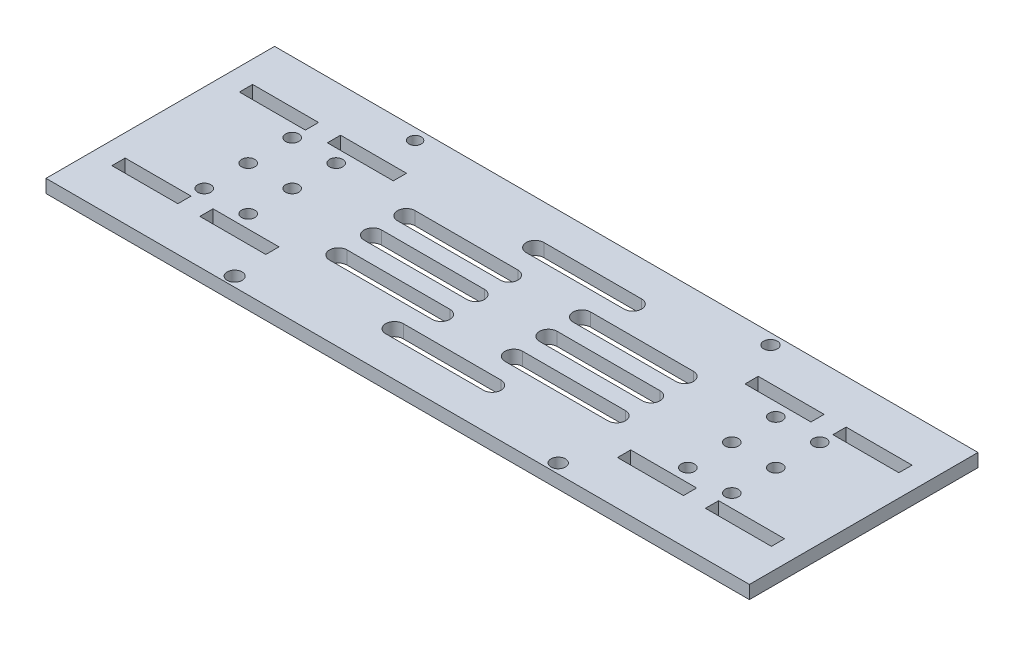
from build123d import *

# Parameters (mm, degrees)
SKETCH1_W           = 160
SKETCH1_H           = 52
SKETCH1_R           = 1.5
SKETCH1_W_2         = 15
SKETCH1_H_2         = 3
BOSS_EXTRUDE1_DEPTH = 3
CUT_EXTRUDE1_DEPTH  = 3
SKETCH3_R           = 1.63582752
SKETCH3_R_2         = 1.692495787
SKETCH3_R_3         = 1.410083192
SKETCH3_R_4         = 1.550817753
CUT_EXTRUDE2_DEPTH  = 10


with BuildPart() as part:
    # Sketch1 → Boss-Extrude1 (new body)
    with BuildSketch(Plane(origin=(0, 0, 0), x_dir=(1, 0, 0), z_dir=(0, 1, 0))):
        Rectangle(SKETCH1_W, SKETCH1_H)
        with Locations((50, 10)):
            Circle(SKETCH1_R, mode=Mode.SUBTRACT)
        with Locations((60, 10)):
            Circle(SKETCH1_R, mode=Mode.SUBTRACT)
        with Locations((60, 0)):
            Circle(SKETCH1_R, mode=Mode.SUBTRACT)
        with Locations((50, 0)):
            Circle(SKETCH1_R, mode=Mode.SUBTRACT)
        with Locations((50, -10)):
            Circle(SKETCH1_R, mode=Mode.SUBTRACT)
        with Locations((60, -10)):
            Circle(SKETCH1_R, mode=Mode.SUBTRACT)
        with Locations((-60, -10)):
            Circle(SKETCH1_R, mode=Mode.SUBTRACT)
        with Locations((-50, -10)):
            Circle(SKETCH1_R, mode=Mode.SUBTRACT)
        with Locations((-50, 0)):
            Circle(SKETCH1_R, mode=Mode.SUBTRACT)
        with Locations((-60, 0)):
            Circle(SKETCH1_R, mode=Mode.SUBTRACT)
        with Locations((-60, 10)):
            Circle(SKETCH1_R, mode=Mode.SUBTRACT)
        with Locations((-50, 10)):
            Circle(SKETCH1_R, mode=Mode.SUBTRACT)
        with Locations((67.5, 14.5)):
            Rectangle(SKETCH1_W_2, SKETCH1_H_2, mode=Mode.SUBTRACT)
        with Locations((47.5, 14.5)):
            Rectangle(SKETCH1_W_2, SKETCH1_H_2, mode=Mode.SUBTRACT)
        with Locations((67.5, -14.5)):
            Rectangle(SKETCH1_W_2, SKETCH1_H_2, mode=Mode.SUBTRACT)
        with Locations((47.5, -14.5)):
            Rectangle(SKETCH1_W_2, SKETCH1_H_2, mode=Mode.SUBTRACT)
        with Locations((-47.5, -14.5)):
            Rectangle(SKETCH1_W_2, SKETCH1_H_2, mode=Mode.SUBTRACT)
        with Locations((-67.5, -14.5)):
            Rectangle(SKETCH1_W_2, SKETCH1_H_2, mode=Mode.SUBTRACT)
        with Locations((-47.5, 14.5)):
            Rectangle(SKETCH1_W_2, SKETCH1_H_2, mode=Mode.SUBTRACT)
        with Locations((-67.5, 14.5)):
            Rectangle(SKETCH1_W_2, SKETCH1_H_2, mode=Mode.SUBTRACT)
    extrude(amount=BOSS_EXTRUDE1_DEPTH)

    # Sketch2 → Cut-Extrude1 (cut)
    with BuildSketch(Plane(origin=(0, 3, 0), x_dir=(1, 0, 0), z_dir=(0, 1, 0))):
        with BuildLine():
            Line((-31.658505885, 2), (-8.266387648, 2))
            ThreePointArc((-8.266387648, 2), (-6.266387648, 0), (-8.266387648, -2))
            Line((-8.266387648, -2), (-31.658505885, -2))
            ThreePointArc((-31.658505885, -2), (-33.658505885, 0), (-31.658505885, 2))
        make_face()
        with BuildLine():
            Line((31.658505885, -9.856733432), (8.266387648, -9.856733432))
            ThreePointArc((8.266387648, -9.856733432), (6.266387648, -7.856733432), (8.266387648, -5.856733432))
            Line((8.266387648, -5.856733432), (31.658505885, -5.856733432))
            ThreePointArc((31.658505885, -5.856733432), (33.658505885, -7.856733432), (31.658505885, -9.856733432))
        make_face()
        with BuildLine():
            Line((-10.747740664, 17.987567994), (11.499478158, 17.987567994))
            ThreePointArc((11.499478158, 17.987567994), (13.499478158, 15.987567994), (11.499478158, 13.987567994))
            Line((11.499478158, 13.987567994), (-10.747740664, 13.987567994))
            ThreePointArc((-10.747740664, 13.987567994), (-12.747740664, 15.987567994), (-10.747740664, 17.987567994))
        make_face()
        with BuildLine():
            Line((-31.658505885, 9.620758334), (-8.266387648, 9.620758334))
            ThreePointArc((-8.266387648, 9.620758334), (-6.266387648, 7.620758334), (-8.266387648, 5.620758334))
            Line((-8.266387648, 5.620758334), (-31.658505885, 5.620758334))
            ThreePointArc((-31.658505885, 5.620758334), (-33.658505885, 7.620758334), (-31.658505885, 9.620758334))
        make_face()
        with BuildLine():
            Line((31.658505885, 5.620758334), (8.266387648, 5.620758334))
            ThreePointArc((8.266387648, 5.620758334), (6.266387648, 7.620758334), (8.266387648, 9.620758334))
            Line((8.266387648, 9.620758334), (31.658505885, 9.620758334))
            ThreePointArc((31.658505885, 9.620758334), (33.658505885, 7.620758334), (31.658505885, 5.620758334))
        make_face()
        with BuildLine():
            Line((-31.658505885, -5.856733432), (-8.266387648, -5.856733432))
            ThreePointArc((-8.266387648, -5.856733432), (-6.266387648, -7.856733432), (-8.266387648, -9.856733432))
            Line((-8.266387648, -9.856733432), (-31.658505885, -9.856733432))
            ThreePointArc((-31.658505885, -9.856733432), (-33.658505885, -7.856733432), (-31.658505885, -5.856733432))
        make_face()
        with BuildLine():
            Line((31.658505885, -2), (8.266387648, -2))
            ThreePointArc((8.266387648, -2), (6.266387648, 0), (8.266387648, 2))
            Line((8.266387648, 2), (31.658505885, 2))
            ThreePointArc((31.658505885, 2), (33.658505885, 0), (31.658505885, -2))
        make_face()
        with BuildLine():
            Line((-10.747740664, -13.987567994), (11.499478158, -13.987567994))
            ThreePointArc((11.499478158, -13.987567994), (13.499478158, -15.987567994), (11.499478158, -17.987567994))
            Line((11.499478158, -17.987567994), (-10.747740664, -17.987567994))
            ThreePointArc((-10.747740664, -17.987567994), (-12.747740664, -15.987567994), (-10.747740664, -13.987567994))
        make_face()
    extrude(amount=-CUT_EXTRUDE1_DEPTH, mode=Mode.SUBTRACT)

    # Sketch3 → Cut-Extrude2 (cut)
    with BuildSketch(Plane(origin=(0, 3, 0), x_dir=(1, 0, 0), z_dir=(0, 1, 0))):
        with Locations((34.323103301, -23.81549711)):
            Circle(SKETCH3_R)
        with Locations((-39.276258797, -23.81549711)):
            Circle(SKETCH3_R_2)
        with Locations((-45.484369153, 23.437784188)):
            Circle(SKETCH3_R_3)
        with Locations((35.235754497, 23.565498985)):
            Circle(SKETCH3_R_4)
    extrude(amount=-CUT_EXTRUDE2_DEPTH, mode=Mode.SUBTRACT)


solid = part.part
